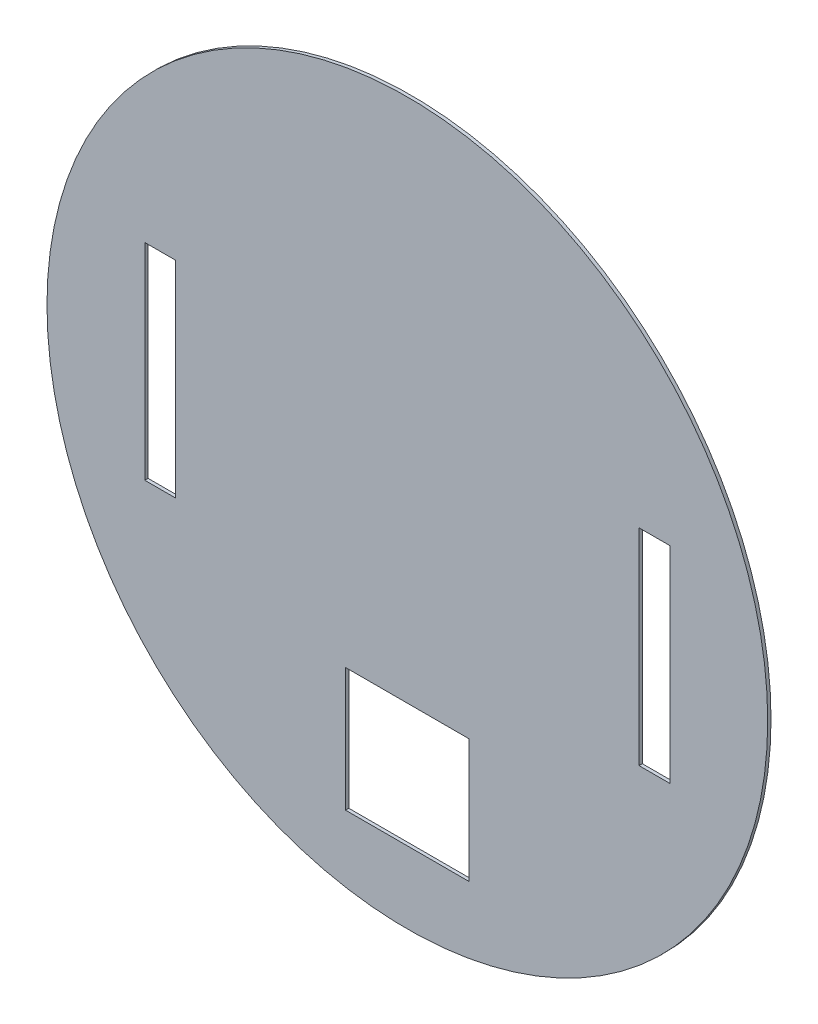
from build123d import *

# Parameters (mm, degrees)
SKETCH1_R           = 175
BOSS_EXTRUDE1_DEPTH = 1.6
SKETCH2_W           = 15
SKETCH2_H           = 100
CUT_EXTRUDE1_DEPTH  = 1.6
SKETCH3_W           = 60
SKETCH3_H           = 60
CUT_EXTRUDE2_DEPTH  = 2.6


with BuildPart() as part:
    # Sketch1 → Boss-Extrude1 (new body)
    with BuildSketch(Plane.XY):
        Circle(SKETCH1_R)
    extrude(amount=BOSS_EXTRUDE1_DEPTH)

    # Sketch2 → Cut-Extrude1 (cut)
    with BuildSketch(Plane.XY.offset(1.6)):
        with Locations((-120, 0)):
            Rectangle(SKETCH2_W, SKETCH2_H)
        with Locations((120, 0)):
            Rectangle(SKETCH2_W, SKETCH2_H)
    extrude(amount=-CUT_EXTRUDE1_DEPTH, mode=Mode.SUBTRACT)

    # Sketch3 → Cut-Extrude2 (cut, through all)
    with BuildSketch(Plane.XY.offset(1.6)):
        with Locations((0, -110)):
            Rectangle(SKETCH3_W, SKETCH3_H)
    extrude(amount=-CUT_EXTRUDE2_DEPTH, mode=Mode.SUBTRACT)


solid = part.part
